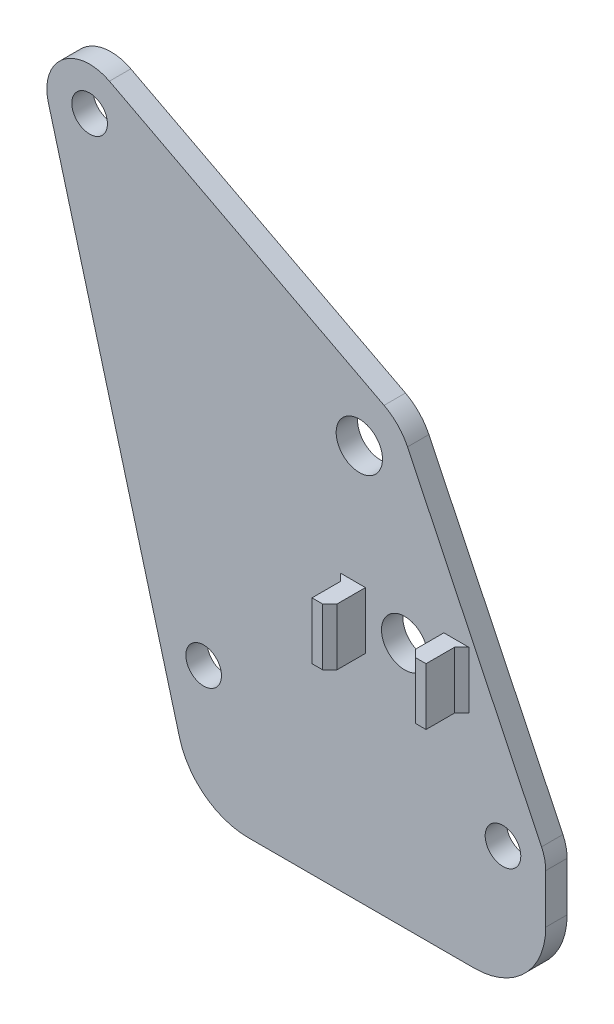
from build123d import *

# Parameters (mm, degrees)
SKETCH1_R           = 2.5
SKETCH1_R_2         = 3.25
BOSS_EXTRUDE1_DEPTH = 3
SKETCH2_W           = 2.5
SKETCH2_H           = 8
BOSS_EXTRUDE2_DEPTH = 5
CHAMFER1_SIZE       = 1
FILLET1_R           = 10


with BuildPart() as part:
    # Sketch1 → Boss-Extrude1 (new body)
    with BuildSketch(Plane.XY):
        with BuildLine():
            Line((-63.791318359, 58.43135993), (-43.395591792, -16.868352188))
            Line((-43.395591792, -16.868352188), (6, -16.868352188))
            Line((6, -16.868352188), (6, 0))
            ThreePointArc((6, 0), (5.850545761, 1.330832182), (5.409628568, 2.595364861))
            Line((5.409628568, 2.595364861), (-13.395576429, 41.791847675))
            ThreePointArc((-13.395576429, 41.791847675), (-14.765199318, 43.760307326), (-16.686113759, 45.195851809))
            Line((-16.686113759, 45.195851809), (-55.222801296, 65.318568168))
            ThreePointArc((-55.222801296, 65.318568168), (-61.758941161, 64.676575814), (-63.791318359, 58.43135993))
        make_face()
        Circle(SKETCH1_R, mode=Mode.SUBTRACT)
        with Locations((-58, 60)):
            Circle(SKETCH1_R, mode=Mode.SUBTRACT)
        with Locations((-42, 0.929027955)):
            Circle(SKETCH1_R, mode=Mode.SUBTRACT)
        with Locations((-20.157612139, 38.547641599)):
            Circle(SKETCH1_R_2, mode=Mode.SUBTRACT)
        with Locations((-13.798527561, 17.748013157)):
            Circle(SKETCH1_R_2, mode=Mode.SUBTRACT)
    extrude(amount=BOSS_EXTRUDE1_DEPTH)

    # Sketch2 → Boss-Extrude2 (add)
    with BuildSketch(Plane.XY.offset(3)):
        with Locations((-7.048527561, 17.748013157)):
            Rectangle(SKETCH2_W, SKETCH2_H)
        with Locations((-20.548527561, 17.748013157)):
            Rectangle(SKETCH2_W, SKETCH2_H)
    extrude(amount=BOSS_EXTRUDE2_DEPTH)

    # Chamfer1
    chamfer1_edges = [part.edges().sort_by_distance(p)[0] for p in [
        (-5.798527561, 17.748013157, 3),
        (-8.298527561, 17.748013157, 8),
        (-21.798527561, 17.748013157, 3),
        (-19.298527561, 17.748013157, 8),
    ]]
    chamfer(chamfer1_edges, length=CHAMFER1_SIZE)

    # Fillet1
    fillet1_edges = [part.edges().sort_by_distance(p)[0] for p in [
        (6, -16.868352188, 1.5),
        (-43.395591792, -16.868352188, 1.5),
    ]]
    fillet(fillet1_edges, radius=FILLET1_R)


solid = part.part
